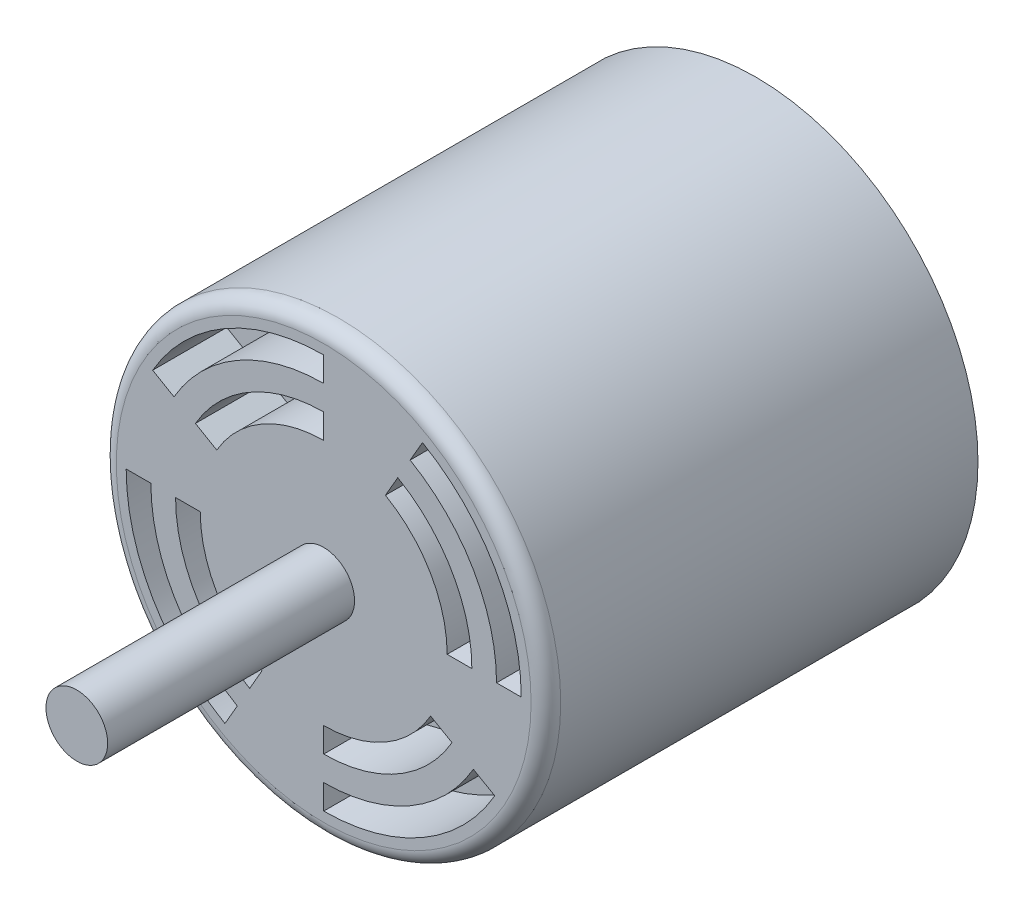
from build123d import *

# Parameters (mm, degrees)
IZIM1_R                     = 22.86
Y_KSEKLIK_EKSTR_ZYON1_DEPTH = 44.45
IZIM2_R                     = 3.175
Y_KSEKLIK_EKSTR_ZYON2_DEPTH = 25.4
KES_EKSTR_ZYON1_DEPTH       = 7.62
RADYUS1_R                   = 1.524


with BuildPart() as part:
    # Çizim1 → Yükseklik-Ekstrüzyon1 (new body)
    with BuildSketch(Plane.XY):
        Circle(IZIM1_R)
    extrude(amount=Y_KSEKLIK_EKSTR_ZYON1_DEPTH)

    # Çizim2 → Yükseklik-Ekstrüzyon2 (add)
    with BuildSketch(Plane.XY.offset(44.45)):
        Circle(IZIM2_R)
    extrude(amount=Y_KSEKLIK_EKSTR_ZYON2_DEPTH)

    # Çizim3 → Kes-Ekstrüzyon1 (cut)
    with BuildSketch(Plane.XY.offset(44.45)):
        with BuildLine():
            Line((12.7, 0), (15.24, 0))
            ThreePointArc((15.24, 0), (13.198227154, 7.62), (7.62, 13.198227154))
            Line((7.62, 13.198227154), (6.35, 10.998522628))
            ThreePointArc((6.35, 10.998522628), (10.998522628, 6.35), (12.7, 0))
        make_face()
        with BuildLine():
            Line((8.89, 15.397931679), (10.16, 17.597636205))
            ThreePointArc((10.16, 17.597636205), (17.597636205, 10.16), (20.32, 0))
            Line((20.32, 0), (17.78, 0))
            ThreePointArc((17.78, 0), (15.397931679, 8.89), (8.89, 15.397931679))
        make_face()
        with BuildLine():
            Line((10.998522628, -6.35), (13.198227154, -7.62))
            ThreePointArc((13.198227154, -7.62), (7.62, -13.198227154), (0, -15.24))
            Line((0, -15.24), (0, -12.7))
            ThreePointArc((0, -12.7), (6.35, -10.998522628), (10.998522628, -6.35))
        make_face()
        with BuildLine():
            Line((0, -17.78), (0, -20.32))
            ThreePointArc((0, -20.32), (10.16, -17.597636205), (17.597636205, -10.16))
            Line((17.597636205, -10.16), (15.397931679, -8.89))
            ThreePointArc((15.397931679, -8.89), (8.89, -15.397931679), (0, -17.78))
        make_face()
        with BuildLine():
            Line((-6.35, -10.998522628), (-7.62, -13.198227154))
            ThreePointArc((-7.62, -13.198227154), (-13.198227154, -7.62), (-15.24, 0))
            Line((-15.24, 0), (-12.7, 0))
            ThreePointArc((-12.7, 0), (-10.998522628, -6.35), (-6.35, -10.998522628))
        make_face()
        with BuildLine():
            Line((-17.78, 0), (-20.32, 0))
            ThreePointArc((-20.32, 0), (-17.597636205, -10.16), (-10.16, -17.597636205))
            Line((-10.16, -17.597636205), (-8.89, -15.397931679))
            ThreePointArc((-8.89, -15.397931679), (-15.397931679, -8.89), (-17.78, 0))
        make_face()
        with BuildLine():
            Line((-10.998522628, 6.35), (-13.198227154, 7.62))
            ThreePointArc((-13.198227154, 7.62), (-7.62, 13.198227154), (0, 15.24))
            Line((0, 15.24), (0, 12.7))
            ThreePointArc((0, 12.7), (-6.35, 10.998522628), (-10.998522628, 6.35))
        make_face()
        with BuildLine():
            Line((0, 17.78), (0, 20.32))
            ThreePointArc((0, 20.32), (-10.16, 17.597636205), (-17.597636205, 10.16))
            Line((-17.597636205, 10.16), (-15.397931679, 8.89))
            ThreePointArc((-15.397931679, 8.89), (-8.89, 15.397931679), (0, 17.78))
        make_face()
    extrude(amount=-KES_EKSTR_ZYON1_DEPTH, mode=Mode.SUBTRACT)

    # Radyus1
    radyus1_edges = [part.edges().sort_by_distance(p)[0] for p in [
        (-22.86, 0, 44.45),
    ]]
    fillet(radyus1_edges, radius=RADYUS1_R)


solid = part.part
